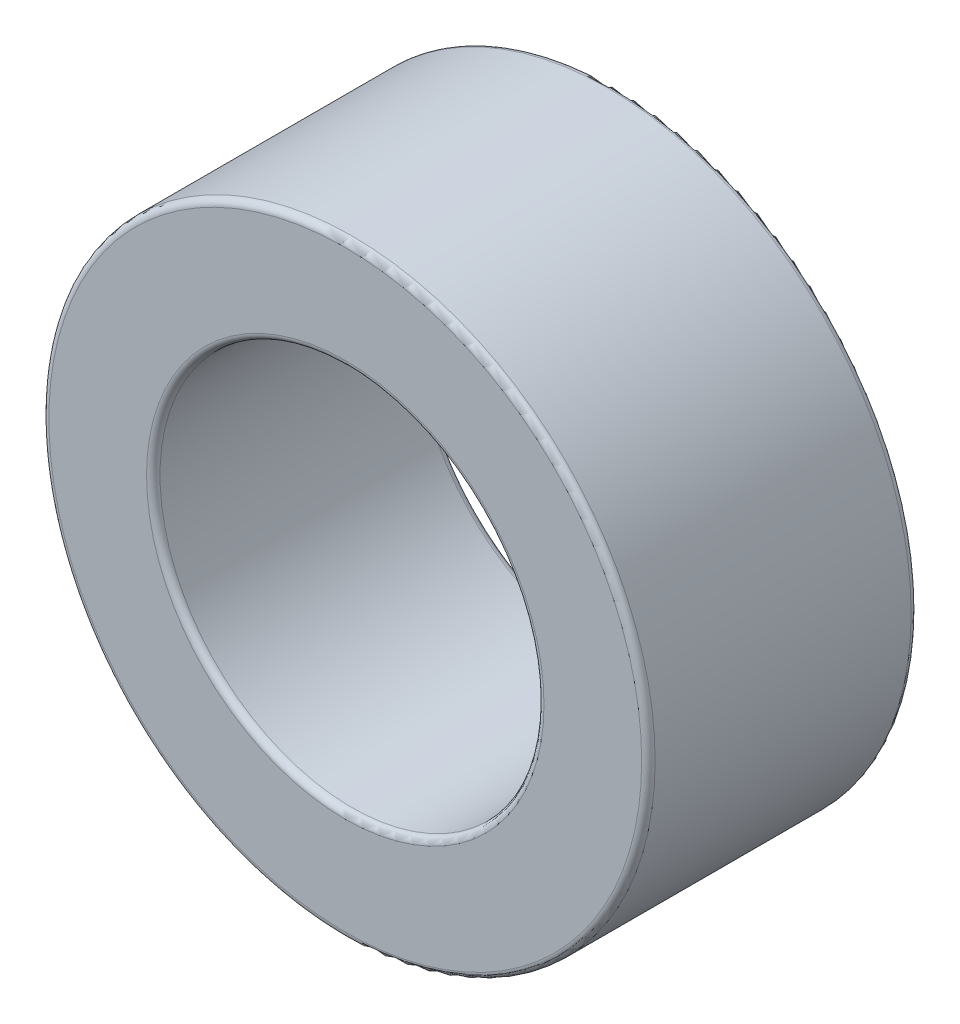
from build123d import *

# Parameters (mm, degrees)
SKETCH_1_R      = 4.5
SKETCH_1_R_2    = 2.85
EXTRUDE_1_DEPTH = 4
FILLET_1_R      = 0.1


with BuildPart() as part:
    # 草图1 → 凸台-拉伸1 (new body)
    with BuildSketch(Plane.XY):
        Circle(SKETCH_1_R)
        Circle(SKETCH_1_R_2, mode=Mode.SUBTRACT)
    extrude(amount=EXTRUDE_1_DEPTH)

    # 圆角1
    fillet_1_edges = [part.edges().sort_by_distance(p)[0] for p in [
        (-4.5, 0, 0),
        (-4.5, 0, 4),
        (-2.85, 0, 0),
        (-2.85, 0, 4),
    ]]
    fillet(fillet_1_edges, radius=FILLET_1_R)


solid = part.part
